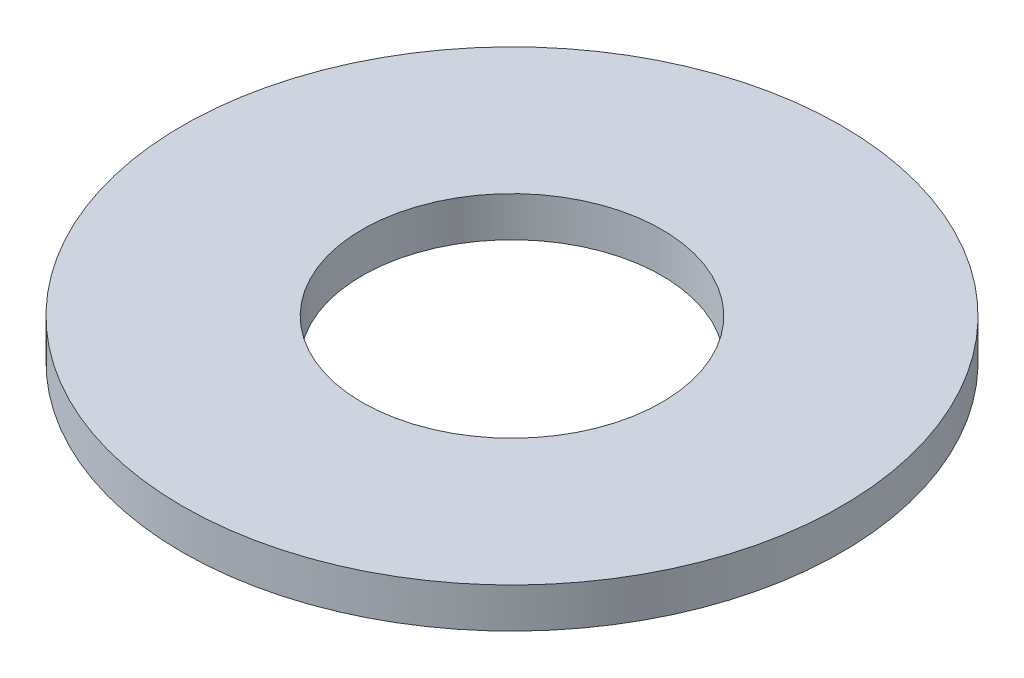
from build123d import *

# Parameters (mm, degrees)
SKETCH1_R           = 82.5
SKETCH1_R_2         = 37.5
BOSS_EXTRUDE1_DEPTH = 10


with BuildPart() as part:
    # Sketch1 → Boss-Extrude1 (new body)
    with BuildSketch(Plane(origin=(0, 0, 0), x_dir=(1, 0, 0), z_dir=(0, 1, 0))):
        Circle(SKETCH1_R)
        Circle(SKETCH1_R_2, mode=Mode.SUBTRACT)
    extrude(amount=BOSS_EXTRUDE1_DEPTH)


solid = part.part
